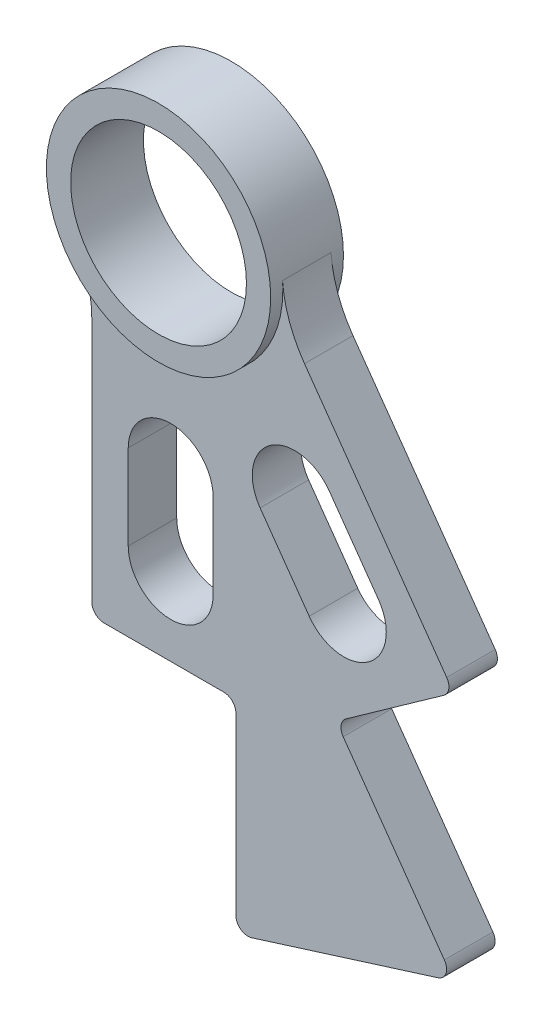
from build123d import *

# Parameters (mm, degrees)
SKETCH1_R           = 11.5062
BOSS_EXTRUDE1_DEPTH = 4.7625
BOSS_EXTRUDE2_DEPTH = 3.175
FILLET2_R           = 1.5875


with BuildPart() as part:
    # Sketch1 → Boss-Extrude1 (new body, symmetric)
    with BuildSketch(Plane.XY):
        with BuildLine():
            ThreePointArc((14.639156809, 1.110279863), (-4.45502565, 13.988937769), (-12.585193267, -7.559797873))
            ThreePointArc((-12.585193267, -7.559797873), (4.45502565, -13.988937769), (14.639156809, 1.110279863))
        make_face()
        Circle(SKETCH1_R, mode=Mode.SUBTRACT)
    extrude(amount=BOSS_EXTRUDE1_DEPTH, both=True)

    # Sketch5 → Boss-Extrude2 (add, symmetric)
    with BuildSketch(Plane.XY):
        with BuildLine():
            ThreePointArc((-12.585193267, -7.559797873), (-10.89585042, -11.492870345), (-10.31875, -15.734319794))
            Line((-10.31875, -15.734319794), (-10.31875, -49.389319794))
            Line((-10.31875, -49.389319794), (8.54075, -49.389319794))
            Line((8.54075, -49.389319794), (8.54075, -76.059319794))
            Line((8.54075, -76.059319794), (37.089554297, -67.094446092))
            Line((37.089554297, -67.094446092), (21.666696712, -45.336128971))
            Line((21.666696712, -45.336128971), (37.052935248, -34.429965394))
            Line((37.052935248, -34.429965394), (17.517315641, -6.869430374))
            ThreePointArc((17.517315641, -6.869430374), (15.535368252, -3.075379389), (14.639156809, 1.110279863))
            ThreePointArc((14.639156809, 1.110279863), (4.45502565, -13.988937769), (-12.585193267, -7.559797873))
        make_face()
        with BuildLine():
            ThreePointArc((5.55625, -39.070569794), (0, -44.626819794), (-5.55625, -39.070569794))
            Line((-5.55625, -39.070569794), (-5.55625, -27.958069794))
            ThreePointArc((-5.55625, -27.958069794), (0, -22.401819794), (5.55625, -27.958069794))
            Line((5.55625, -27.958069794), (5.55625, -39.070569794))
        make_face(mode=Mode.SUBTRACT)
        with BuildLine():
            ThreePointArc((27.200344435, -28.7656506), (25.880457031, -36.511728663), (18.134378968, -35.19184126))
            Line((18.134378968, -35.19184126), (11.708188308, -26.125875793))
            ThreePointArc((11.708188308, -26.125875793), (13.028075711, -18.379797729), (20.774153775, -19.699685133))
            Line((20.774153775, -19.699685133), (27.200344435, -28.7656506))
        make_face(mode=Mode.SUBTRACT)
    extrude(amount=BOSS_EXTRUDE2_DEPTH, both=True)

    # Fillet2
    fillet2_edges = [part.edges().sort_by_distance(p)[0] for p in [
        (37.089554297, -67.094446092, 0),
        (21.666696712, -45.336128971, 0),
        (37.052935248, -34.429965394, 0),
        (-10.31875, -49.389319794, 0),
        (8.54075, -49.389319794, 0),
        (8.54075, -76.059319794, 0),
    ]]
    fillet(fillet2_edges, radius=FILLET2_R)


solid = part.part
